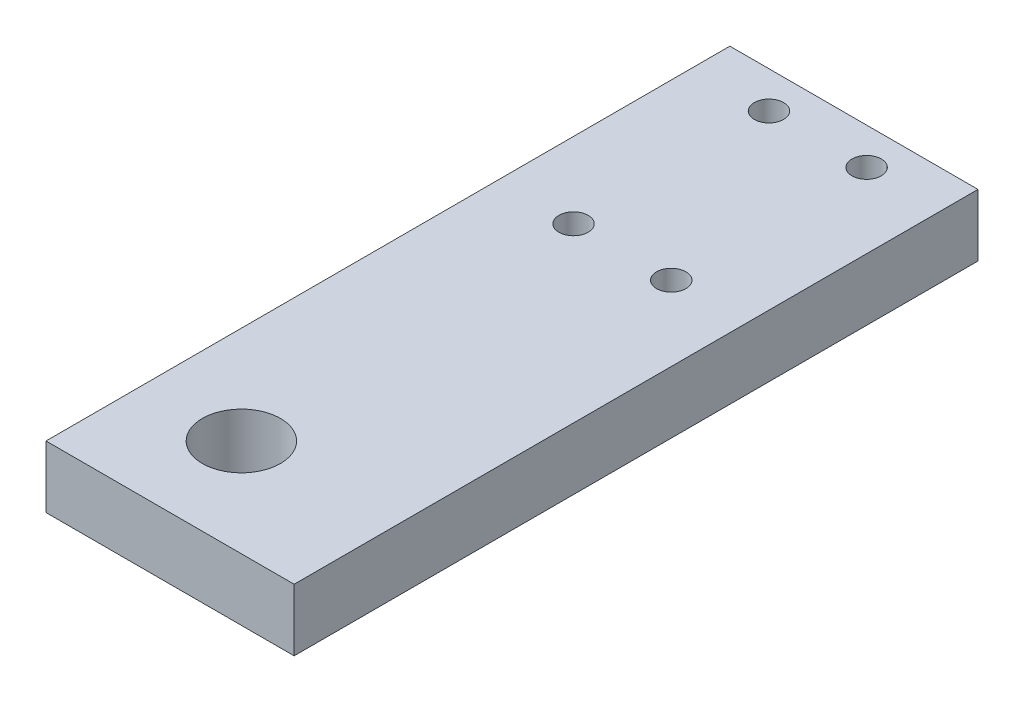
from build123d import *

# Parameters (mm, degrees)
SKETCH2_W           = 101.6
SKETCH2_H           = 280
BOSS_EXTRUDE1_DEPTH = 25.4
SKETCH3_R           = 6
CUT_EXTRUDE1_DEPTH  = 25.4
SKETCH4_R           = 16
CUT_EXTRUDE2_DEPTH  = 25.4


with BuildPart() as part:
    # Sketch2 → Boss-Extrude1 (new body)
    with BuildSketch(Plane(origin=(0, 0, 0), x_dir=(1, 0, 0), z_dir=(0, 1, 0))):
        with Locations((50.8, 140)):
            Rectangle(SKETCH2_W, SKETCH2_H)
    extrude(amount=BOSS_EXTRUDE1_DEPTH)

    # Sketch3 → Cut-Extrude1 (cut)
    with BuildSketch(Plane(origin=(0, 25.4, 0), x_dir=(1, 0, 0), z_dir=(0, 1, 0))):
        with Locations((71, 265)):
            Circle(SKETCH3_R)
        with Locations((31, 265)):
            Circle(SKETCH3_R)
        with Locations((31, 185)):
            Circle(SKETCH3_R)
        with Locations((71, 185)):
            Circle(SKETCH3_R)
    extrude(amount=-CUT_EXTRUDE1_DEPTH, mode=Mode.SUBTRACT)

    # Sketch4 → Cut-Extrude2 (cut)
    with BuildSketch(Plane(origin=(0, 25.4, 0), x_dir=(1, 0, 0), z_dir=(0, 1, 0))):
        with Locations((40, 40)):
            Circle(SKETCH4_R)
    extrude(amount=-CUT_EXTRUDE2_DEPTH, mode=Mode.SUBTRACT)


solid = part.part
